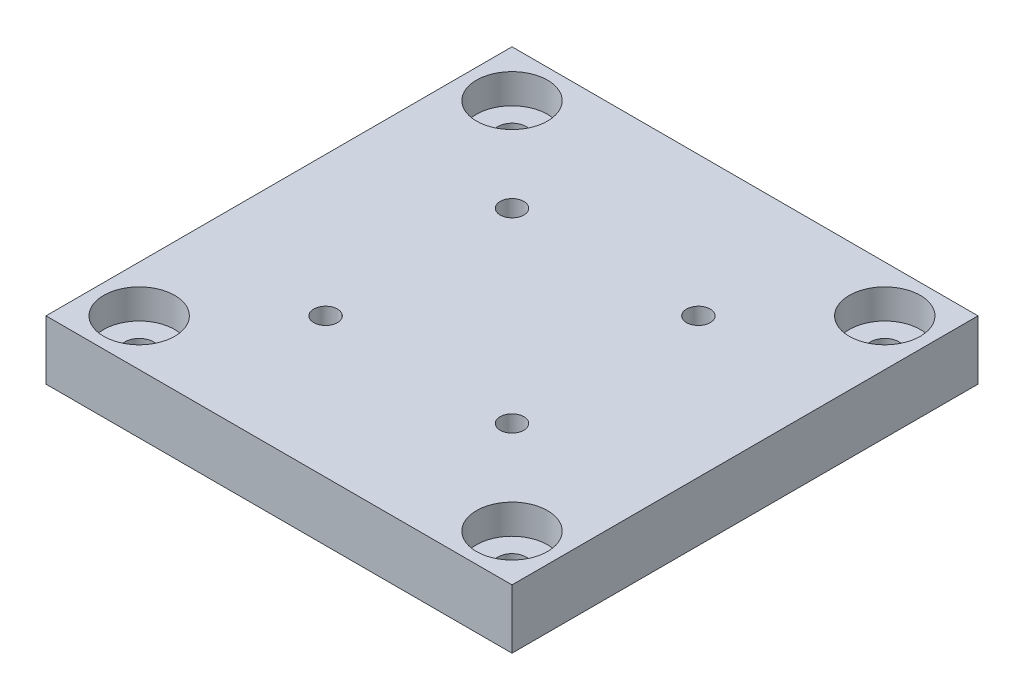
from build123d import *

# Parameters (mm, degrees)
SKETCH1_W           = 49.9999
SKETCH1_H           = 49.9999
SKETCH1_R           = 1.524
SKETCH1_R_2         = 1.27
BOSS_EXTRUDE1_DEPTH = 6.35
SKETCH2_R           = 3.81
CUT_EXTRUDE1_DEPTH  = 3.175


with BuildPart() as part:
    # Sketch1 → Boss-Extrude1 (new body)
    with BuildSketch(Plane(origin=(0, 0, 0), x_dir=(1, 0, 0), z_dir=(0, 1, 0))):
        with Locations((24.99995, 24.99995)):
            Rectangle(SKETCH1_W, SKETCH1_H)
        with Locations((4.9999392, 44.9999608)):
            Circle(SKETCH1_R, mode=Mode.SUBTRACT)
        with Locations((44.9999608, 44.9999608)):
            Circle(SKETCH1_R, mode=Mode.SUBTRACT)
        with Locations((44.9999608, 4.9999392)):
            Circle(SKETCH1_R, mode=Mode.SUBTRACT)
        with Locations((4.9999392, 4.9999392)):
            Circle(SKETCH1_R, mode=Mode.SUBTRACT)
        with Locations((14.9999446, 34.9999554)):
            Circle(SKETCH1_R_2, mode=Mode.SUBTRACT)
        with Locations((34.9999554, 34.9999554)):
            Circle(SKETCH1_R_2, mode=Mode.SUBTRACT)
        with Locations((34.9999554, 14.9999446)):
            Circle(SKETCH1_R_2, mode=Mode.SUBTRACT)
        with Locations((14.9999446, 14.9999446)):
            Circle(SKETCH1_R_2, mode=Mode.SUBTRACT)
    extrude(amount=BOSS_EXTRUDE1_DEPTH)

    # Sketch2 → Cut-Extrude1 (cut)
    with BuildSketch(Plane(origin=(0, 6.35, 0), x_dir=(1, 0, 0), z_dir=(0, 1, 0))):
        with Locations((4.9999392, 44.9999608)):
            Circle(SKETCH2_R)
        with Locations((44.9999608, 44.9999608)):
            Circle(SKETCH2_R)
        with Locations((4.9999392, 4.9999392)):
            Circle(SKETCH2_R)
        with Locations((44.9999608, 4.9999392)):
            Circle(SKETCH2_R)
    extrude(amount=-CUT_EXTRUDE1_DEPTH, mode=Mode.SUBTRACT)


solid = part.part
